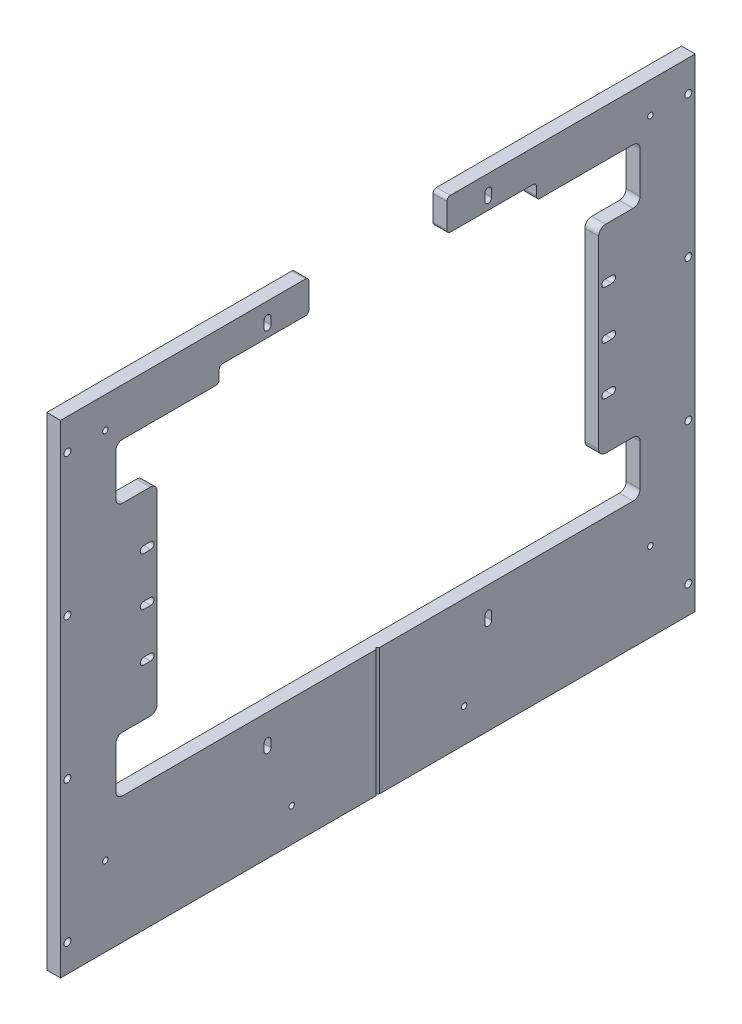
from build123d import *

# Parameters (mm, degrees)
SKETCH1_W                 = 12.7
SKETCH1_H                 = 444.5
EXTRUDE1_DEPTH            = 292.1
EXTRUDE1_DEPTH_BACK       = 292.1
CUT_EXTRUDE1_REACH        = 14.7
CUT_EXTRUDE2_REACH        = 14.7
SKETCH5_W                 = 127
SKETCH5_H                 = 43.65625
FILLET2_R                 = 6.35
M6X1_0_TAPPED_HOLE1_D     = 5
M6X1_0_TAPPED_HOLE1_DEPTH = 12.7
SKETCH11_W                = 292.1
SKETCH11_H                = 14.2875
CUT_EXTRUDE3_DEPTH        = 13.7
FILLET3_R                 = 3.175
CUT_EXTRUDE7_DEPTH        = 1
CUT_EXTRUDE7_DEPTH_BACK   = 445.5
CUT_EXTRUDE8_REACH        = 14.7
M6X1_0_TAPPED_HOLE2_D     = 5
M6X1_0_TAPPED_HOLE2_DEPTH = 12.7
M6_CLEARANCE_HOLE1_D      = 6.4
M6_CLEARANCE_HOLE1_DEPTH  = 12.7
CUT_EXTRUDE9_DEPTH        = 13.7
CUT_EXTRUDE10_DEPTH       = 13.7


with BuildPart() as part:
    # Sketch1 → Extrude1 (new body, two sides)
    with BuildSketch(Plane.XY) as extrude1_sk:
        Rectangle(SKETCH1_W, SKETCH1_H)
    extrude(amount=EXTRUDE1_DEPTH)
    extrude(extrude1_sk.sketch, amount=-EXTRUDE1_DEPTH_BACK)

    # Sketch4 → Cut-Extrude1 (cut, up to next)
    with BuildSketch(Plane(origin=(6.35, 0, 0), x_dir=(0, 0, -1), z_dir=(1, 0, 0)), mode=Mode.PRIVATE) as cut_extrude1_sk1:
        Polygon((203.2, 127.79375), (241.3, 127.79375), (241.3, 178.59375), (-241.3, 178.59375), (-241.3, 127.79375), (-203.2, 127.79375), (-203.2, -54.76875), (-241.3, -54.76875), (-241.3, -105.56875), (241.3, -105.56875), (241.3, -54.76875), (203.2, -54.76875), align=None)
    cut_extrude1_tool1 = extrude(cut_extrude1_sk1.sketch, amount=-CUT_EXTRUDE1_REACH, mode=Mode.PRIVATE) & part.part
    add(cut_extrude1_tool1.solids().sort_by_distance((6.35, 36.5125, 0))[0], mode=Mode.SUBTRACT)

    # Sketch5 → Cut-Extrude2 (cut, up to next)
    with BuildSketch(Plane(origin=(6.35, 0, 0), x_dir=(0, 0, -1), z_dir=(1, 0, 0)), mode=Mode.PRIVATE) as cut_extrude2_sk1:
        with Locations((0, 200.421875)):
            Rectangle(SKETCH5_W, SKETCH5_H)
    cut_extrude2_tool1 = extrude(cut_extrude2_sk1.sketch, amount=-CUT_EXTRUDE2_REACH, mode=Mode.PRIVATE) & part.part
    add(cut_extrude2_tool1.solids().sort_by_distance((6.35, 200.421875, 0))[0], mode=Mode.SUBTRACT)

    # Fillet2
    fillet2_edges = [part.edges().sort_by_distance(p)[0] for p in [
        (0, 127.79375, -203.2),
        (0, -54.76875, -203.2),
        (0, -54.76875, -241.3),
        (0, -105.56875, -241.3),
        (0, -105.56875, 241.3),
        (0, -54.76875, 241.3),
        (0, -54.76875, 203.2),
        (0, 127.79375, 203.2),
        (0, 127.79375, 241.3),
        (0, 178.59375, 241.3),
        (0, 178.59375, -241.3),
        (0, 127.79375, -241.3),
    ]]
    fillet(fillet2_edges, radius=FILLET2_R)

    # M6x1.0 Tapped Hole1
    with Locations(Plane(origin=(6.35, 0, 0), x_dir=(0, 0, -1), z_dir=(1, 0, 0))):
        with Locations((101.6, 204.7875), (-101.6, 204.7875), (101.6, -132.23875), (-101.6, -132.23875)):
            Hole(M6X1_0_TAPPED_HOLE1_D / 2, depth=M6X1_0_TAPPED_HOLE1_DEPTH)

    # Sketch11 → Cut-Extrude3 (cut, through all)
    with BuildSketch(Plane(origin=(6.35, 0, 0), x_dir=(0, 0, -1), z_dir=(1, 0, 0))):
        with Locations((0, 185.7375)):
            Rectangle(SKETCH11_W, SKETCH11_H)
    extrude(amount=-CUT_EXTRUDE3_DEPTH, mode=Mode.SUBTRACT)

    # Fillet3
    fillet3_edges = [part.edges().sort_by_distance(p)[0] for p in [
        (0, 192.88125, 63.5),
        (0, 192.88125, -63.5),
        (0, 192.88125, 146.05),
        (0, 178.59375, -146.05),
        (0, 178.59375, 146.05),
        (0, 192.88125, -146.05),
        (0, 222.25, 63.5),
        (0, 222.25, -63.5),
    ]]
    fillet(fillet3_edges, radius=FILLET3_R)

    # Sketch18 → Cut-Extrude7 (cut, two sides)
    with BuildSketch(Plane.XZ.offset(222.25)) as cut_extrude7_sk:
        Polygon((6.35, 1.5875), (6.35, -1.5875), (4.7625, 0), align=None)
    extrude(amount=CUT_EXTRUDE7_DEPTH, mode=Mode.SUBTRACT)
    extrude(cut_extrude7_sk.sketch, amount=-CUT_EXTRUDE7_DEPTH_BACK, mode=Mode.SUBTRACT)

    # Sketch19 → Cut-Extrude8 (cut, up to next)
    with BuildSketch(Plane(origin=(6.35, 0, 0), x_dir=(0, 0, -1), z_dir=(1, 0, 0)), mode=Mode.PRIVATE) as cut_extrude8_sk1:
        with BuildLine():
            Line((104.775, 207.9625), (104.775, 201.6125))
            ThreePointArc((104.775, 201.6125), (101.6, 198.4375), (98.425, 201.6125))
            Line((98.425, 201.6125), (98.425, 207.9625))
            ThreePointArc((98.425, 207.9625), (101.6, 211.1375), (104.775, 207.9625))
        make_face()
    cut_extrude8_tool1 = extrude(cut_extrude8_sk1.sketch, amount=-CUT_EXTRUDE8_REACH, mode=Mode.PRIVATE) & part.part
    add(cut_extrude8_tool1.solids().sort_by_distance((6.35, 204.7875, -101.6))[0], mode=Mode.SUBTRACT)
    # Sketch19 → Cut-Extrude8 (cut, up to next)
    with BuildSketch(Plane(origin=(6.35, 0, 0), x_dir=(0, 0, -1), z_dir=(1, 0, 0)), mode=Mode.PRIVATE) as cut_extrude8_sk2:
        with BuildLine():
            Line((-98.425, 207.9625), (-98.425, 201.6125))
            ThreePointArc((-98.425, 201.6125), (-101.6, 198.4375), (-104.775, 201.6125))
            Line((-104.775, 201.6125), (-104.775, 207.9625))
            ThreePointArc((-104.775, 207.9625), (-101.6, 211.1375), (-98.425, 207.9625))
        make_face()
    cut_extrude8_tool2 = extrude(cut_extrude8_sk2.sketch, amount=-CUT_EXTRUDE8_REACH, mode=Mode.PRIVATE) & part.part
    add(cut_extrude8_tool2.solids().sort_by_distance((6.35, 204.7875, 101.6))[0], mode=Mode.SUBTRACT)
    # Sketch19 → Cut-Extrude8 (cut, up to next)
    with BuildSketch(Plane(origin=(6.35, 0, 0), x_dir=(0, 0, -1), z_dir=(1, 0, 0)), mode=Mode.PRIVATE) as cut_extrude8_sk3:
        with BuildLine():
            Line((-98.425, -129.06375), (-98.425, -135.41375))
            ThreePointArc((-98.425, -135.41375), (-101.6, -138.58875), (-104.775, -135.41375))
            Line((-104.775, -135.41375), (-104.775, -129.06375))
            ThreePointArc((-104.775, -129.06375), (-101.6, -125.88875), (-98.425, -129.06375))
        make_face()
    cut_extrude8_tool3 = extrude(cut_extrude8_sk3.sketch, amount=-CUT_EXTRUDE8_REACH, mode=Mode.PRIVATE) & part.part
    add(cut_extrude8_tool3.solids().sort_by_distance((6.35, -132.23875, 101.6))[0], mode=Mode.SUBTRACT)
    # Sketch19 → Cut-Extrude8 (cut, up to next)
    with BuildSketch(Plane(origin=(6.35, 0, 0), x_dir=(0, 0, -1), z_dir=(1, 0, 0)), mode=Mode.PRIVATE) as cut_extrude8_sk4:
        with BuildLine():
            Line((104.775, -129.06375), (104.775, -135.41375))
            ThreePointArc((104.775, -135.41375), (101.6, -138.58875), (98.425, -135.41375))
            Line((98.425, -135.41375), (98.425, -129.06375))
            ThreePointArc((98.425, -129.06375), (101.6, -125.88875), (104.775, -129.06375))
        make_face()
    cut_extrude8_tool4 = extrude(cut_extrude8_sk4.sketch, amount=-CUT_EXTRUDE8_REACH, mode=Mode.PRIVATE) & part.part
    add(cut_extrude8_tool4.solids().sort_by_distance((6.35, -132.23875, -101.6))[0], mode=Mode.SUBTRACT)

    # M6x1.0 Tapped Hole2
    with Locations(Plane(origin=(6.35, 0, 0), x_dir=(0, 0, -1), z_dir=(1, 0, 0))):
        with Locations((79.375, -191.29375), (-79.375, -191.29375), (250.825, -149.225), (250.825, 193.675), (-250.825, 193.675), (-250.825, -149.225)):
            Hole(M6X1_0_TAPPED_HOLE2_D / 2, depth=M6X1_0_TAPPED_HOLE2_DEPTH)

    # M6 Clearance Hole1
    with Locations(Plane(origin=(6.35, 0, 0), x_dir=(0, 0, -1), z_dir=(1, 0, 0))):
        with Locations((-285.75, -196.85), (-285.75, -66.675), (-285.75, 193.675), (-285.75, 63.5), (285.75, 193.675), (285.75, 63.5), (285.75, -66.675), (285.75, -196.85)):
            Hole(M6_CLEARANCE_HOLE1_D / 2, depth=M6_CLEARANCE_HOLE1_DEPTH)

    # Sketch27 → Cut-Extrude9 (cut, through all)
    with BuildSketch(Plane.ZY.offset(6.35)):
        with BuildLine():
            Line((-209.2325, 33.3375), (-215.5825, 33.3375))
            ThreePointArc((-215.5825, 33.3375), (-218.7575, 36.5125), (-215.5825, 39.6875))
            Line((-215.5825, 39.6875), (-209.2325, 39.6875))
            ThreePointArc((-209.2325, 39.6875), (-206.0575, 36.5125), (-209.2325, 33.3375))
        make_face()
    cut_extrude9 = extrude(amount=-CUT_EXTRUDE9_DEPTH, mode=Mode.SUBTRACT)

    # Mirror1: Cut-Extrude9 across plane
    add(cut_extrude9.mirror(Plane.XY), mode=Mode.SUBTRACT)

    # Sketch29 → Cut-Extrude10 (cut, through all)
    with BuildSketch(Plane(origin=(6.35, 0, 0), x_dir=(0, 0, -1), z_dir=(1, 0, 0))):
        with BuildLine():
            Line((-215.5825, 84.1375), (-209.2325, 84.1375))
            ThreePointArc((-209.2325, 84.1375), (-206.0575, 80.9625), (-209.2325, 77.7875))
            Line((-209.2325, 77.7875), (-215.5825, 77.7875))
            ThreePointArc((-215.5825, 77.7875), (-218.7575, 80.9625), (-215.5825, 84.1375))
        make_face()
        with BuildLine():
            Line((-215.5825, -4.7625), (-209.2325, -4.7625))
            ThreePointArc((-209.2325, -4.7625), (-206.0575, -7.9375), (-209.2325, -11.1125))
            Line((-209.2325, -11.1125), (-215.5825, -11.1125))
            ThreePointArc((-215.5825, -11.1125), (-218.7575, -7.9375), (-215.5825, -4.7625))
        make_face()
    cut_extrude10 = extrude(amount=-CUT_EXTRUDE10_DEPTH, mode=Mode.SUBTRACT)

    # Mirror2: Cut-Extrude10 across plane
    add(cut_extrude10.mirror(Plane.XY), mode=Mode.SUBTRACT)


solid = part.part
